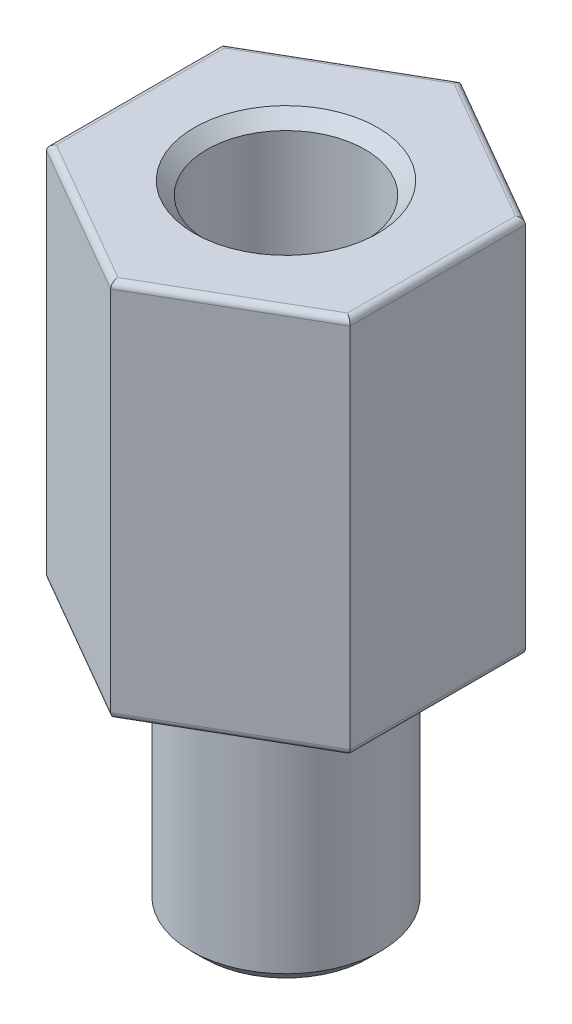
from build123d import *

# Parameters (mm, degrees)
SKETCH_2_R            = 1.5
EXTRUDE_1_DEPTH       = 4
EXTRUDE_2_DEPTH       = 6
FILLET_1_R            = 0.1
HOLE_WIZARD_M31_D     = 2.5
HOLE_WIZARD_M31_DEPTH = 5
HOLE_WIZARD_M31_TIP   = 0.751075774
CHAMFER_2_SIZE        = 0.2


with BuildPart() as part:
    # Эскиз2 → Бобышка-Вытянуть1 (new body)
    with BuildSketch(Plane(origin=(0, 0, 0), x_dir=(1, 0, 0), z_dir=(0, 1, 0))):
        Circle(SKETCH_2_R)
    extrude(amount=EXTRUDE_1_DEPTH)

    # Эскиз3 → Бобышка-Вытянуть2 (add)
    with BuildSketch(Plane(origin=(0, 4, 0), x_dir=(1, 0, 0), z_dir=(0, 1, 0))):
        Polygon((-2.4, 1.385640646), (-2.4, -1.385640646), (0, -2.771281292), (2.4, -1.385640646), (2.4, 1.385640646), (0, 2.771281292), align=None)
    extrude(amount=EXTRUDE_2_DEPTH)

    # Скругление1
    fillet_1_edges = [part.edges().sort_by_distance(p)[0] for p in [
        (-1.2, 4, -2.078460969),
        (-2.4, 4, 0),
        (-1.2, 4, 2.078460969),
        (1.2, 4, 2.078460969),
        (2.4, 4, 0),
        (1.2, 4, -2.078460969),
        (-1.2, 10, -2.078460969),
        (-2.4, 10, 0),
        (-1.2, 10, 2.078460969),
        (1.2, 10, 2.078460969),
        (2.4, 10, 0),
        (1.2, 10, -2.078460969),
    ]]
    fillet(fillet_1_edges, radius=FILLET_1_R)

    # Отверстие обработанное метчиком M31
    with Locations(Plane.ZX.offset(10)):
        with Locations((0, 0)):
            Hole(HOLE_WIZARD_M31_D / 2, depth=HOLE_WIZARD_M31_DEPTH)
            with Locations((0, 0, -(HOLE_WIZARD_M31_DEPTH + HOLE_WIZARD_M31_TIP / 2))):  # 118° drill point
                Cone(0, HOLE_WIZARD_M31_D / 2, HOLE_WIZARD_M31_TIP, mode=Mode.SUBTRACT)

    # Фаска2
    chamfer_2_edges = [part.edges().sort_by_distance(p)[0] for p in [
        (-1.5, 0, 0),
        (0, 10, 1.25),
    ]]
    chamfer(chamfer_2_edges, length=CHAMFER_2_SIZE)


solid = part.part
